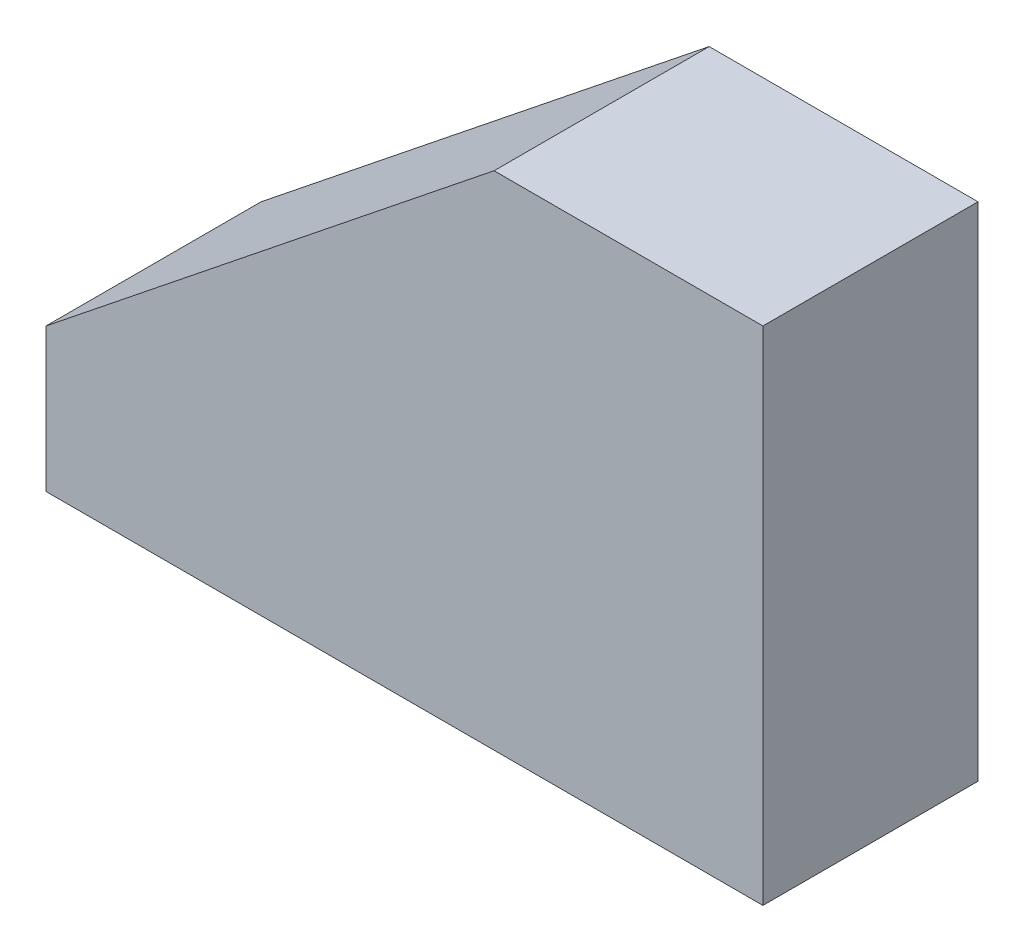
from build123d import *

# Parameters (mm, degrees)
SKETCH1_W           = 400
SKETCH1_H           = 120
BOSS_EXTRUDE1_DEPTH = 40
BOSS_EXTRUDE2_DEPTH = 120
BOSS_EXTRUDE3_DEPTH = 120


with BuildPart() as part:
    # Sketch1 → Boss-Extrude1 (new body, symmetric)
    with BuildSketch(Plane(origin=(0, 0, 0), x_dir=(1, 0, 0), z_dir=(0, 1, 0))):
        Rectangle(SKETCH1_W, SKETCH1_H)
    extrude(amount=BOSS_EXTRUDE1_DEPTH, both=True)

    # Sketch3 → Boss-Extrude2 (add)
    with BuildSketch(Plane.XY.offset(60)):
        Polygon((-200, 40), (50, 240), (200, 240), (200, 40), align=None)
    extrude(amount=-BOSS_EXTRUDE2_DEPTH)


with BuildPart() as body_2:
    # Sketch4 → Boss-Extrude3 (new body)
    with BuildSketch(Plane.XY.offset(60)):
        Polygon((-200, -40), (200, -40), (200, 240), (50, 240), (-200, 40), align=None)
    extrude(amount=-BOSS_EXTRUDE3_DEPTH)


solid = Compound([part.part, body_2.part])
